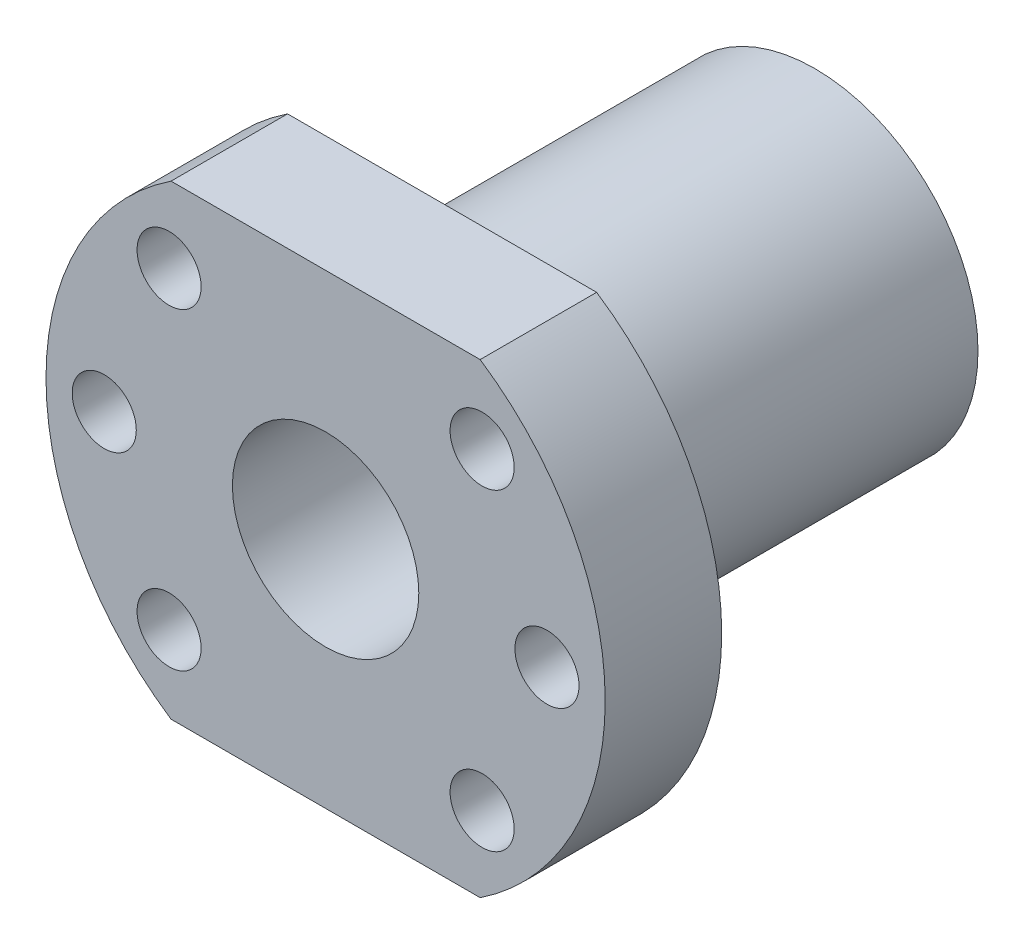
from build123d import *

# Parameters (mm, degrees)
SKETCH1_R            = 14
SKETCH1_R_2          = 8
BOSS_EXTRUDE1_DEPTH  = 42
SKETCH2_R            = 8
BOSS_EXTRUDE2_DEPTH  = 10
M5_CLEARANCE_HOLE1_D = 5.5


with BuildPart() as part:
    # Sketch1 → Boss-Extrude1 (new body)
    with BuildSketch(Plane.XY):
        Circle(SKETCH1_R)
        Circle(SKETCH1_R_2, mode=Mode.SUBTRACT)
    extrude(amount=-BOSS_EXTRUDE1_DEPTH)

    # Sketch2 → Boss-Extrude2 (add)
    with BuildSketch(Plane.XY):
        with BuildLine():
            Line((13.266499161, 20), (-13.266499161, 20))
            ThreePointArc((-13.266499161, 20), (-24, 0), (-13.266499161, -20))
            Line((-13.266499161, -20), (13.266499161, -20))
            ThreePointArc((13.266499161, -20), (21.147056295, -11.349097324), (24, 0))
            ThreePointArc((24, 0), (21.147056295, 11.349097324), (13.266499161, 20))
        make_face()
        Circle(SKETCH2_R, mode=Mode.SUBTRACT)
    extrude(amount=-BOSS_EXTRUDE2_DEPTH)

    # M5 Clearance Hole1 (through all)
    with Locations(Plane.XY):
        with Locations((-19, 0), (-13.435028843, 13.435028843), (13.435028843, -13.435028843), (0, 0), (13.435028843, 13.435028843), (-13.435028843, -13.435028843), (19, 0)):
            Hole(M5_CLEARANCE_HOLE1_D / 2)


solid = part.part
